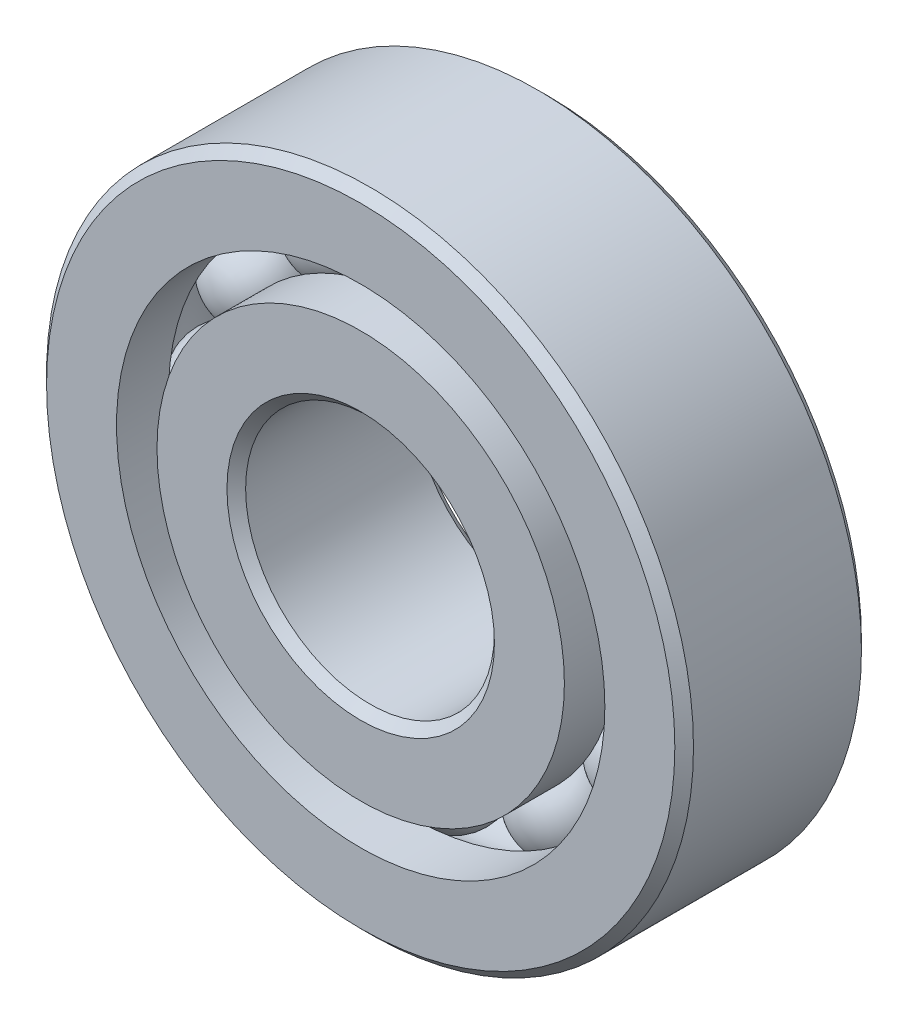
from build123d import *

# Parameters (mm, degrees)
CIRPATTERN1_COUNT = 12


with BuildPart() as part:
    # Sketch1 → Revolve1 (revolve)
    with BuildSketch(Plane(origin=(0, 0, 0), x_dir=(0, 0, -1), z_dir=(1, 0, 0))):
        with BuildLine():
            Line((6.75, 26), (-6.75, 26))
            Line((-6.75, 26), (-7.5, 25.25))
            Line((-7.5, 25.25), (-7.5, 19.626373626))
            Line((-7.5, 19.626373626), (-3.333333333, 19.626373626))
            ThreePointArc((-3.333333333, 19.626373626), (0, 21.708935465), (3.333333333, 19.626373626))
            Line((3.333333333, 19.626373626), (7.5, 19.626373626))
            Line((7.5, 19.626373626), (7.5, 25.25))
            Line((7.5, 25.25), (6.75, 26))
        make_face()
    revolve(axis=Axis((0, 0, 7.5), (0, 0, -1)))


with BuildPart() as body_2:
    # Sketch3 → Revolve3 (revolve)
    with BuildSketch(Plane(origin=(0, 0, 0), x_dir=(0, 0, -1), z_dir=(1, 0, 0))):
        with BuildLine():
            Line((-7.5, 16.373626374), (-3.333333333, 16.373626374))
            ThreePointArc((-3.333333333, 16.373626374), (0, 14.291064535), (3.333333333, 16.373626374))
            Line((3.333333333, 16.373626374), (7.5, 16.373626374))
            Line((7.5, 16.373626374), (7.5, 10.75))
            Line((7.5, 10.75), (6.75, 10))
            Line((6.75, 10), (-6.75, 10))
            Line((-6.75, 10), (-7.5, 10.75))
            Line((-7.5, 10.75), (-7.5, 16.373626374))
        make_face()
    revolve(axis=Axis((0, 0, 7.5), (0, 0, -1)))


with BuildPart() as body_3:
    # Sketch4 → Revolve4 (revolve)
    with BuildSketch(Plane(origin=(0, 0, 0), x_dir=(0, 0, -1), z_dir=(1, 0, 0))):
        with BuildLine():
            Line((-3.708935465, 18), (3.708935465, 18))
            ThreePointArc((3.708935465, 18), (0, 21.708935465), (-3.708935465, 18))
        make_face()
    revolve(axis=Axis((0, 18, 3.708935465), (0, 0, -1)))


with BuildPart() as cirpattern1_1:
    # CirPattern1: pattern copy
    add(body_3.part.rotate(Axis((0, 0, -7.5), (0, 0, 1)), 1 * 360 / CIRPATTERN1_COUNT))


with BuildPart() as cirpattern1_2:
    # CirPattern1: pattern copy
    add(body_3.part.rotate(Axis((0, 0, -7.5), (0, 0, 1)), 2 * 360 / CIRPATTERN1_COUNT))


with BuildPart() as cirpattern1_3:
    # CirPattern1: pattern copy
    add(body_3.part.rotate(Axis((0, 0, -7.5), (0, 0, 1)), 3 * 360 / CIRPATTERN1_COUNT))


with BuildPart() as cirpattern1_4:
    # CirPattern1: pattern copy
    add(body_3.part.rotate(Axis((0, 0, -7.5), (0, 0, 1)), 4 * 360 / CIRPATTERN1_COUNT))


with BuildPart() as cirpattern1_5:
    # CirPattern1: pattern copy
    add(body_3.part.rotate(Axis((0, 0, -7.5), (0, 0, 1)), 5 * 360 / CIRPATTERN1_COUNT))


with BuildPart() as cirpattern1_6:
    # CirPattern1: pattern copy
    add(body_3.part.rotate(Axis((0, 0, -7.5), (0, 0, 1)), 6 * 360 / CIRPATTERN1_COUNT))


with BuildPart() as cirpattern1_7:
    # CirPattern1: pattern copy
    add(body_3.part.rotate(Axis((0, 0, -7.5), (0, 0, 1)), 7 * 360 / CIRPATTERN1_COUNT))


with BuildPart() as cirpattern1_8:
    # CirPattern1: pattern copy
    add(body_3.part.rotate(Axis((0, 0, -7.5), (0, 0, 1)), 8 * 360 / CIRPATTERN1_COUNT))


with BuildPart() as cirpattern1_9:
    # CirPattern1: pattern copy
    add(body_3.part.rotate(Axis((0, 0, -7.5), (0, 0, 1)), 9 * 360 / CIRPATTERN1_COUNT))


with BuildPart() as cirpattern1_10:
    # CirPattern1: pattern copy
    add(body_3.part.rotate(Axis((0, 0, -7.5), (0, 0, 1)), 10 * 360 / CIRPATTERN1_COUNT))


with BuildPart() as cirpattern1_11:
    # CirPattern1: pattern copy
    add(body_3.part.rotate(Axis((0, 0, -7.5), (0, 0, 1)), 11 * 360 / CIRPATTERN1_COUNT))


solid = Compound([part.part, body_2.part, body_3.part, cirpattern1_1.part, cirpattern1_2.part, cirpattern1_3.part, cirpattern1_4.part, cirpattern1_5.part, cirpattern1_6.part, cirpattern1_7.part, cirpattern1_8.part, cirpattern1_9.part, cirpattern1_10.part, cirpattern1_11.part])
